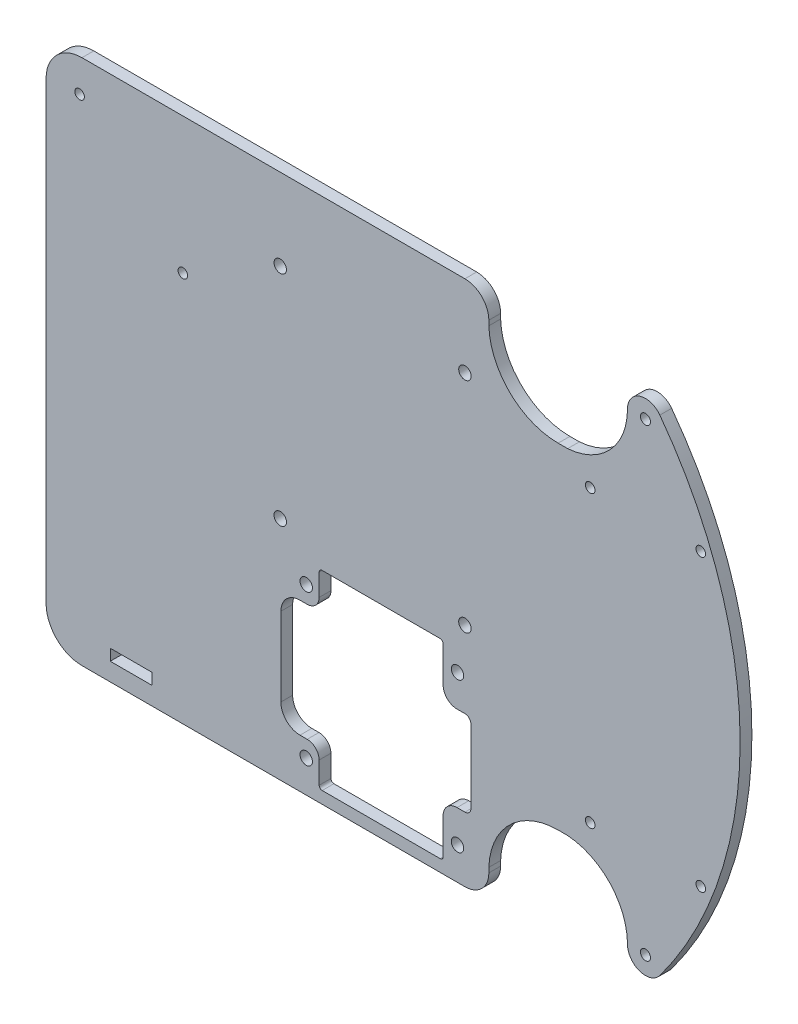
from build123d import *

# Parameters (mm, degrees)
CROQUIS1_W              = 184.15
CROQUIS1_H              = 139.7
SALIENTE_EXTRUIR1_DEPTH = 3.1242
CROQUIS2_R              = 1.3335
CORTAR_EXTRUIR1_DEPTH   = 116.613964341
CROQUIS9_R              = 1.27
CORTAR_EXTRUIR6_DEPTH   = 116.613964341
CORTAR_EXTRUIR2_DEPTH   = 116.613964341
CROQUIS5_R              = 1.651
DRIVER_DEPTH            = 116.613964341
CROQUIS6_R              = 1.651
RASPI_DEPTH             = 116.613964341
CROQUIS8_R              = 1.27
CORTAR_EXTRUIR5_DEPTH   = 116.613964341
CROQUIS7_W              = 11.1125
CROQUIS7_H              = 2.9972
CORTAR_EXTRUIR7_DEPTH   = 116.613964341


with BuildPart() as part:
    # Croquis1 → Saliente-Extruir1 (new body)
    with BuildSketch(Plane.XY):
        Rectangle(CROQUIS1_W, CROQUIS1_H)
    extrude(amount=SALIENTE_EXTRUIR1_DEPTH)

    # Croquis2 → Cortar-Extruir1 (cut, through all)
    with BuildSketch(Plane.XY.offset(3.1242)):
        with BuildLine():
            ThreePointArc((68.2879, 61.5442), (67.636840382, 62.689842778), (66.3194, 62.716802767))
            Line((66.3194, 62.716802767), (66.3194, 60.371597233))
            ThreePointArc((66.3194, 60.371597233), (67.636840382, 60.398557222), (68.2879, 61.5442))
        make_face()
        with BuildLine():
            Line((66.3194, 60.371597233), (66.3194, 62.716802767))
            ThreePointArc((66.3194, 62.716802767), (65.6209, 61.5442), (66.3194, 60.371597233))
        make_face()
        with Locations(Location((66.9544, -61.5442, 0), (0, 0, 180))):
            Circle(CROQUIS2_R)
    extrude(amount=-CORTAR_EXTRUIR1_DEPTH, mode=Mode.SUBTRACT)

    # Croquis9 → Cortar-Extruir6 (cut, through all)
    with BuildSketch(Plane.XY.offset(3.1242)):
        with Locations((52.2859, 38.4937)):
            Circle(CROQUIS9_R)
        with Locations((81.6229, 38.4937)):
            Circle(CROQUIS9_R)
        with Locations(Location((81.6229, -38.4937, 0), (0, 0, 180))):
            Circle(CROQUIS9_R)
        with Locations(Location((52.2859, -38.4937, 0), (0, 0, 180))):
            Circle(CROQUIS9_R)
    extrude(amount=-CORTAR_EXTRUIR6_DEPTH, mode=Mode.SUBTRACT)

    # Croquis3 → Cortar-Extruir2 (cut, through all)
    with BuildSketch(Plane.XY.offset(3.1242)):
        with BuildLine():
            ThreePointArc((19.05, 69.85), (23.540128061, 67.990128061), (25.4, 63.5))
            Line((25.4, 63.5), (25.4, 62.214355717))
            ThreePointArc((25.4, 62.214355717), (31.009401302, 49.616015934), (43.79595, 44.45))
            Line((43.79595, 44.45), (46.307334449, 44.45))
            ThreePointArc((46.307334449, 44.45), (57.607742834, 49.876604957), (62.1919, 61.5442))
            ThreePointArc((62.1919, 61.5442), (65.45872604, 66.06574461), (70.77746038, 64.384202742))
            ThreePointArc((70.77746038, 64.384202742), (86.61242756, 33.907634674), (92.075, 0))
            Line((92.075, 0), (92.075, 69.85))
            Line((92.075, 69.85), (19.05, 69.85))
        make_face()
        with BuildLine():
            Line((92.075, -69.85), (92.075, 0))
            ThreePointArc((92.075, 0), (86.61242756, -33.907634674), (70.77746038, -64.384202742))
            ThreePointArc((70.77746038, -64.384202742), (65.45872604, -66.06574461), (62.1919, -61.5442))
            ThreePointArc((62.1919, -61.5442), (57.607742834, -49.876604957), (46.307334449, -44.45))
            Line((46.307334449, -44.45), (43.79595, -44.45))
            ThreePointArc((43.79595, -44.45), (31.009401302, -49.616015934), (25.4, -62.214355717))
            Line((25.4, -62.214355717), (25.4, -63.5))
            ThreePointArc((25.4, -63.5), (23.540128061, -67.990128061), (19.05, -69.85))
            Line((19.05, -69.85), (92.075, -69.85))
        make_face()
        with BuildLine():
            ThreePointArc((-92.075, 60.325), (-89.285192091, 67.060192091), (-82.55, 69.85))
            Line((-82.55, 69.85), (-92.075, 69.85))
            Line((-92.075, 69.85), (-92.075, 60.325))
        make_face()
        with BuildLine():
            Line((-92.075, -69.85), (-82.55, -69.85))
            ThreePointArc((-82.55, -69.85), (-89.285192091, -67.060192091), (-92.075, -60.325))
            Line((-92.075, -60.325), (-92.075, -69.85))
        make_face()
    extrude(amount=-CORTAR_EXTRUIR2_DEPTH, mode=Mode.SUBTRACT)

    # Croquis5 → Driver (cut, through all)
    with BuildSketch(Plane.XY.offset(3.1242)):
        with BuildLine():
            Line((12.47775, -16.1036), (-18.82775, -16.1036))
            ThreePointArc((-18.82775, -16.1036), (-19.389016008, -16.336083992), (-19.6215, -16.89735))
            Line((-19.6215, -16.89735), (-19.6215, -22.7076))
            ThreePointArc((-19.6215, -22.7076), (-20.55143597, -24.95266403), (-22.7965, -25.8826))
            Line((-22.7965, -25.8826), (-24.7015, -25.8826))
            ThreePointArc((-24.7015, -25.8826), (-28.293602448, -27.370497552), (-29.7815, -30.9626))
            Line((-29.7815, -30.9626), (-29.7815, -51.816))
            ThreePointArc((-29.7815, -51.816), (-28.293602448, -55.408102448), (-24.7015, -56.896))
            Line((-24.7015, -56.896), (-22.7965, -56.896))
            ThreePointArc((-22.7965, -56.896), (-20.55143597, -57.82593597), (-19.6215, -60.071))
            Line((-19.6215, -60.071), (-19.6215, -65.88125))
            ThreePointArc((-19.6215, -65.88125), (-19.389016008, -66.442516008), (-18.82775, -66.675))
            Line((-18.82775, -66.675), (12.47775, -66.675))
            ThreePointArc((12.47775, -66.675), (13.039016008, -66.442516008), (13.2715, -65.88125))
            Line((13.2715, -65.88125), (13.2715, -56.388))
            ThreePointArc((13.2715, -56.388), (14.350225725, -53.783725725), (16.9545, -52.705))
            Line((16.9545, -52.705), (19.05, -52.705))
            ThreePointArc((19.05, -52.705), (20.172532015, -52.240032015), (20.6375, -51.1175))
            Line((20.6375, -51.1175), (20.6375, -31.6611))
            ThreePointArc((20.6375, -31.6611), (20.172532015, -30.538567985), (19.05, -30.0736))
            Line((19.05, -30.0736), (16.9545, -30.0736))
            ThreePointArc((16.9545, -30.0736), (14.350225725, -28.994874275), (13.2715, -26.3906))
            Line((13.2715, -26.3906), (13.2715, -16.89735))
            ThreePointArc((13.2715, -16.89735), (13.039016008, -16.336083992), (12.47775, -16.1036))
        make_face()
        with Locations((17.0815, -21.5646)):
            Circle(CROQUIS5_R)
        with Locations((-23.0505, -21.4376)):
            Circle(CROQUIS5_R)
        with Locations(Location((17.0815, -61.214, 0), (0, 0, 180))):
            Circle(CROQUIS5_R)
        with Locations(Location((-23.0505, -61.341, 0), (0, 0, 180))):
            Circle(CROQUIS5_R)
    extrude(amount=-DRIVER_DEPTH, mode=Mode.SUBTRACT)

    # Croquis6 → RasPi (cut, through all)
    with BuildSketch(Plane.XY.offset(3.1242)):
        with Locations((-29.95, 48.2464)):
            Circle(CROQUIS6_R)
        with Locations((19.05, 48.2464)):
            Circle(CROQUIS6_R)
        with Locations((19.05, -9.7536)):
            Circle(CROQUIS6_R)
        with Locations((-29.95, -9.7536)):
            Circle(CROQUIS6_R)
    extrude(amount=-RASPI_DEPTH, mode=Mode.SUBTRACT)

    # Croquis8 → Cortar-Extruir5 (cut, through all)
    with BuildSketch(Plane.XY.offset(3.1242)):
        with Locations((-83.185, 61.138037406)):
            Circle(CROQUIS8_R)
        with Locations((-55.795218831, 33.748256237)):
            Circle(CROQUIS8_R)
    extrude(amount=-CORTAR_EXTRUIR5_DEPTH, mode=Mode.SUBTRACT)

    # Croquis7 → Cortar-Extruir7 (cut, through all)
    with BuildSketch(Plane.XY.offset(3.1242)):
        with Locations((-69.490109415, -63.5889)):
            Rectangle(CROQUIS7_W, CROQUIS7_H)
    extrude(amount=-CORTAR_EXTRUIR7_DEPTH, mode=Mode.SUBTRACT)


solid = part.part
